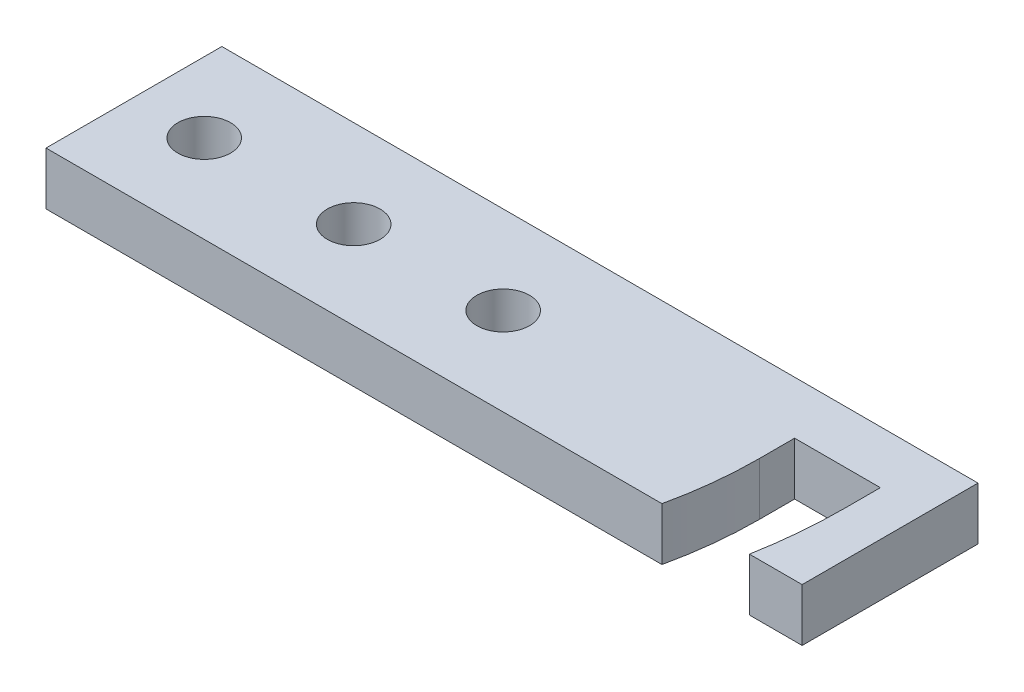
from build123d import *

# Parameters (mm, degrees)
ESQUISSE1_R             = 1.5
BOSS_EXTRU_2_DEPTH      = 3
ENL_V_MAT_EXTRU_2_DEPTH = 3
ESQUISSE3_W             = 4.875673512
ESQUISSE3_H             = 2
ENL_V_MAT_EXTRU_3_DEPTH = 3


with BuildPart() as part:
    # Esquisse1 → Boss.-Extru.2 (new body)
    with BuildSketch(Plane(origin=(0, 0, 0), x_dir=(1, 0, 0), z_dir=(0, 1, 0))):
        Polygon((0, 0), (36.5, 0), (36.5, 2.820303555), (40, 2.820303555), (40, 0), (43, 0), (43, 10), (0, 10), align=None)
        with Locations((4, 4.99734883)):
            Circle(ESQUISSE1_R, mode=Mode.SUBTRACT)
        with Locations((12.5, 4.99734883)):
            Circle(ESQUISSE1_R, mode=Mode.SUBTRACT)
        with Locations((21, 4.99734883)):
            Circle(ESQUISSE1_R, mode=Mode.SUBTRACT)
    extrude(amount=BOSS_EXTRU_2_DEPTH)

    # Esquisse2 → Enlèv. mat.-Extru.2 (cut)
    with BuildSketch(Plane(origin=(0, 3, 0), x_dir=(1, 0, 0), z_dir=(0, 1, 0))):
        with BuildLine():
            Line((35.602803426, 4.99734883), (40.450375585, 4.99734883))
            ThreePointArc((40.450375585, 4.99734883), (40.337553987, 2.488547647), (40, 0))
            Line((40, 0), (40, 2.820303555))
            Line((40, 2.820303555), (36.5, 2.820303555))
            Line((36.5, 2.820303555), (36.5, 0))
            Line((36.5, 0), (35.02705885, 0))
            ThreePointArc((35.02705885, 0), (35.437382668, 2.483715582), (35.574702073, 4.99734883))
            Line((35.574702073, 4.99734883), (35.602803426, 4.99734883))
        make_face()
    extrude(amount=-ENL_V_MAT_EXTRU_2_DEPTH, mode=Mode.SUBTRACT)

    # Esquisse3 → Enlèv. mat.-Extru.3 (cut)
    with BuildSketch(Plane(origin=(0, 3, 0), x_dir=(1, 0, 0), z_dir=(0, 1, 0))):
        with Locations((38.012538829, 5.99734883)):
            Rectangle(ESQUISSE3_W, ESQUISSE3_H)
    extrude(amount=-ENL_V_MAT_EXTRU_3_DEPTH, mode=Mode.SUBTRACT)


solid = part.part
